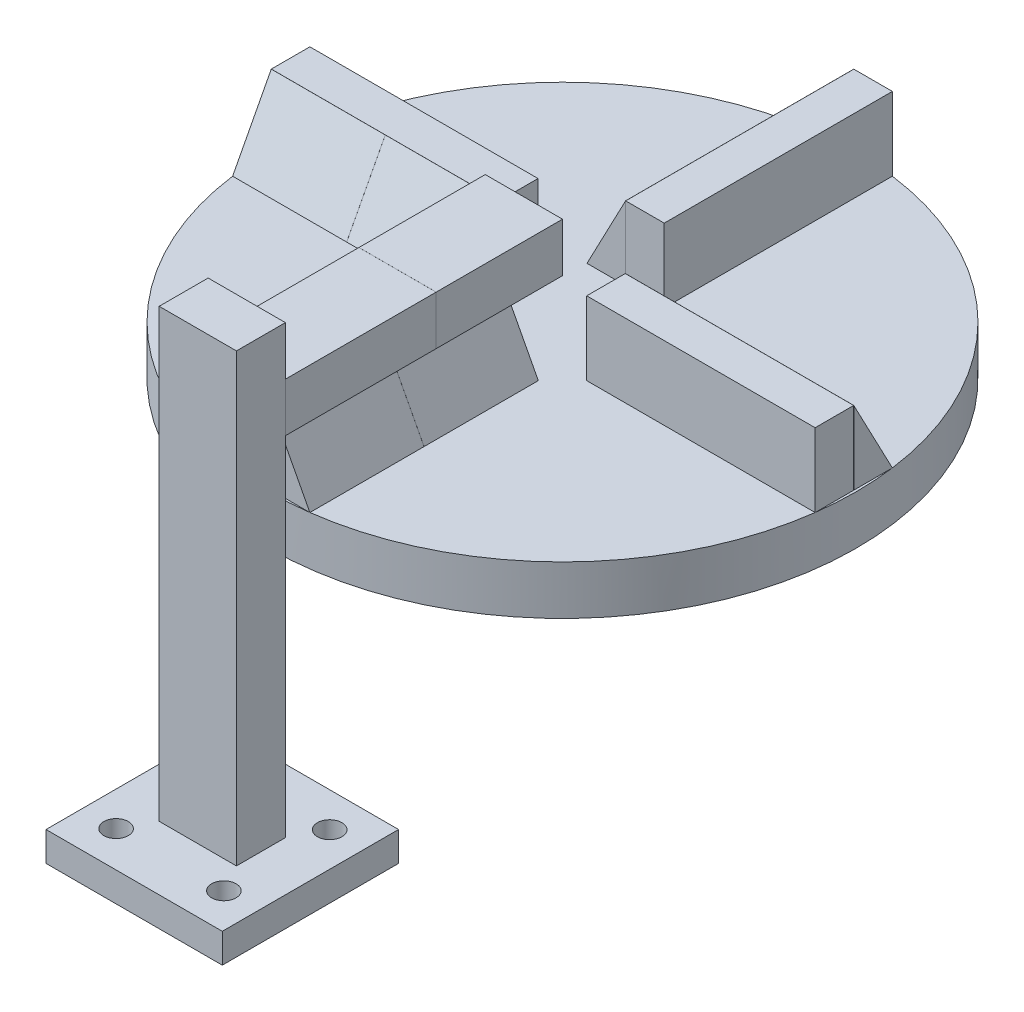
from build123d import *

# Parameters (mm, degrees)
SKETCH1_R                = 60
BOSS_EXTRUDE1_DEPTH      = 10
SKETCH2_R                = 1.5
CUT_EXTRUDE1_DEPTH       = 4
SKETCH3_W                = 15.7752901
SKETCH3_H                = 46.65078099
SKETCH3_W_2              = 46.65078099
SKETCH3_H_2              = 15.7752901
BOSS_EXTRUDE2_DEPTH      = 15
CUT_EXTRUDE2_DEPTH       = 120.479282574
SKETCH5_W                = 0.01
SKETCH5_H                = 15
CUT_EXTRUDE3_DEPTH       = 120.479282574
SKETCH6_W                = 0.01
SKETCH6_H                = 16.947417043
CUT_EXTRUDE4_DEPTH       = 7
CUT_EXTRUDE5_DEPTH       = 120.479282574
SKETCH9_W                = 0.01
SKETCH9_H                = 15
CUT_EXTRUDE6_DEPTH       = 120.479282574
SKETCH12_W               = 15.7752901
SKETCH12_H               = 10
BOSS_EXTRUDE3_DEPTH      = 51.591638
SKETCH14_W               = 15.7752901
SKETCH14_H               = 10
BOSS_EXTRUDE4_DEPTH      = 5
SKETCH13_W               = 0.01
SKETCH13_H               = 10
CUT_EXTRUDE9_DEPTH       = 68.88764505
SKETCH15_W               = 15.7752901
SKETCH15_H               = 10
BOSS_EXTRUDE5_DEPTH      = 10
SKETCH16_W               = 15.7752901
SKETCH16_H               = 10
BOSS_EXTRUDE6_DEPTH      = 10
BOSS_EXTRUDE6_DEPTH_BACK = 54
SKETCH17_W               = 0.01
SKETCH17_H               = 10
CUT_EXTRUDE10_DEPTH      = 68.88764505
SKETCH18_W               = 15.7752901
SKETCH18_H               = 15
CUT_EXTRUDE11_DEPTH      = 46.650781
SKETCH19_W               = 7.87764505
SKETCH19_H               = 15
CUT_EXTRUDE12_DEPTH      = 46.650781
SKETCH20_W               = 46.591637524
SKETCH20_H               = 15.7752901
SKETCH20_W_2             = 15.7752901
SKETCH20_H_2             = 46.591637524
BOSS_EXTRUDE12_DEPTH     = 15
CUT_EXTRUDE13_DEPTH      = 46.591638
CUT_EXTRUDE14_DEPTH      = 51.591638
SKETCH23_W               = 0.01
SKETCH23_H               = 15
CUT_EXTRUDE15_DEPTH      = 48
SKETCH24_W               = 0.01
SKETCH24_H               = 15
CUT_EXTRUDE16_DEPTH      = 48
SKETCH26_W               = 0.01
SKETCH26_H               = 16.947417043
CUT_EXTRUDE18_DEPTH      = 5
SKETCH28_W               = 0.01
SKETCH28_H               = 16.947417043
CUT_EXTRUDE20_DEPTH      = 6
SKETCH29_W               = 0.01
SKETCH29_H               = 16.947417043
CUT_EXTRUDE21_DEPTH      = 6
SKETCH30_W               = 15.7752901
SKETCH30_H               = 10
BOSS_EXTRUDE13_DEPTH     = 33.09
SKETCH31_W               = 36
SKETCH31_H               = 36
BOSS_EXTRUDE14_DEPTH     = 6
SKETCH32_R               = 2.5
CUT_EXTRUDE22_DEPTH      = 6


with BuildPart() as part:
    # Sketch1 → Boss-Extrude1 (new body)
    with BuildSketch(Plane(origin=(0, 0, 0), x_dir=(1, 0, 0), z_dir=(0, 1, 0))):
        Circle(SKETCH1_R)
    extrude(amount=BOSS_EXTRUDE1_DEPTH)

    # Sketch2 → Cut-Extrude1 (cut)
    with BuildSketch(Plane.XZ):
        Circle(SKETCH2_R)
    extrude(amount=-CUT_EXTRUDE1_DEPTH, mode=Mode.SUBTRACT)

    # Sketch3 → Boss-Extrude2 (add)
    with BuildSketch(Plane(origin=(0, 10, 0), x_dir=(1, 0, 0), z_dir=(0, 1, 0))):
        with Locations((0, -36.153892079)):
            Rectangle(SKETCH3_W, SKETCH3_H)
        with Locations((-36.153892079, 0)):
            Rectangle(SKETCH3_W_2, SKETCH3_H_2)
        with Locations((0, 36.153892079)):
            Rectangle(SKETCH3_W, SKETCH3_H)
        with Locations((36.153892079, 0)):
            Rectangle(SKETCH3_W_2, SKETCH3_H_2)
    extrude(amount=BOSS_EXTRUDE2_DEPTH)

    # Sketch4 → Cut-Extrude2 (cut, through all)
    with BuildSketch(Plane.XY.offset(59.479282574)):
        Polygon((0, 25), (7.88764505, 10), (7.88764505, 25), align=None)
    extrude(amount=-CUT_EXTRUDE2_DEPTH, mode=Mode.SUBTRACT)

    # Sketch5 → Cut-Extrude3 (cut, through all)
    with BuildSketch(Plane.XY.offset(59.479282574)):
        with Locations((-0.005, 17.5)):
            Rectangle(SKETCH5_W, SKETCH5_H)
    extrude(amount=-CUT_EXTRUDE3_DEPTH, mode=Mode.SUBTRACT)

    # Sketch6 → Cut-Extrude4 (cut)
    with BuildSketch(Plane(origin=(10.298443557, 5.41536449, 0), x_dir=(0, 0, -1), z_dir=(0.885090628, 0.465418714, 0))):
        with Locations((-36.158892079, 13.653557188)):
            Rectangle(SKETCH6_W, SKETCH6_H)
    extrude(amount=-CUT_EXTRUDE4_DEPTH, mode=Mode.SUBTRACT)

    # Sketch8 → Cut-Extrude5 (cut, through all)
    with BuildSketch(Plane(origin=(59.479282574, 0, 0), x_dir=(0, 0, -1), z_dir=(1, 0, 0))):
        Polygon((0, 25), (7.88764505, 10), (7.88764505, 25), align=None)
    extrude(amount=-CUT_EXTRUDE5_DEPTH, mode=Mode.SUBTRACT)

    # Sketch9 → Cut-Extrude6 (cut, through all)
    with BuildSketch(Plane(origin=(59.479282574, 0, 0), x_dir=(0, 0, -1), z_dir=(1, 0, 0))):
        with Locations((-0.005, 17.5)):
            Rectangle(SKETCH9_W, SKETCH9_H)
    extrude(amount=-CUT_EXTRUDE6_DEPTH, mode=Mode.SUBTRACT)

    # Sketch18 → Cut-Extrude11 (cut)
    with BuildSketch(Plane(origin=(0, 0, -59.479282574), x_dir=(-1, 0, 0), z_dir=(0, 0, -1))):
        with Locations((0, 17.5)):
            Rectangle(SKETCH18_W, SKETCH18_H)
    extrude(amount=-CUT_EXTRUDE11_DEPTH, mode=Mode.SUBTRACT)

    # Sketch19 → Cut-Extrude12 (cut)
    with BuildSketch(Plane.ZY.offset(59.479282574)):
        with Locations((3.948822525, 17.5)):
            Rectangle(SKETCH19_W, SKETCH19_H)
        Polygon((-7.88764505, 10), (0, 10), (0, 25), align=None)
    extrude(amount=-CUT_EXTRUDE12_DEPTH, mode=Mode.SUBTRACT)

    # Sketch20 → Boss-Extrude12 (add)
    with BuildSketch(Plane(origin=(0, 10, 0), x_dir=(1, 0, 0), z_dir=(0, 1, 0))):
        with Locations((-36.183463812, 0)):
            Rectangle(SKETCH20_W, SKETCH20_H)
        with Locations((0, 36.183463812)):
            Rectangle(SKETCH20_W_2, SKETCH20_H_2)
    extrude(amount=BOSS_EXTRUDE12_DEPTH)

    # Sketch21 → Cut-Extrude13 (cut)
    with BuildSketch(Plane(origin=(0, 0, -59.479282574), x_dir=(-1, 0, 0), z_dir=(0, 0, -1))):
        Polygon((0, 25), (7.88764505, 10), (7.88764505, 25), (1.000443781, 25), align=None)
    extrude(amount=-CUT_EXTRUDE13_DEPTH, mode=Mode.SUBTRACT)

    # Sketch22 → Cut-Extrude14 (cut)
    with BuildSketch(Plane.ZY.offset(59.479282574)):
        Polygon((0, 25), (7.88764505, 10), (7.88764505, 25), align=None)
    extrude(amount=-CUT_EXTRUDE14_DEPTH, mode=Mode.SUBTRACT)

    # Sketch23 → Cut-Extrude15 (cut)
    with BuildSketch(Plane.ZY.offset(59.479282574)):
        with Locations((-0.005, 17.5)):
            Rectangle(SKETCH23_W, SKETCH23_H)
    extrude(amount=-CUT_EXTRUDE15_DEPTH, mode=Mode.SUBTRACT)

    # Sketch24 → Cut-Extrude16 (cut)
    with BuildSketch(Plane(origin=(0, 0, -59.479282574), x_dir=(-1, 0, 0), z_dir=(0, 0, -1))):
        with Locations((-0.005, 17.5)):
            Rectangle(SKETCH24_W, SKETCH24_H)
    extrude(amount=-CUT_EXTRUDE16_DEPTH, mode=Mode.SUBTRACT)

    # Sketch26 → Cut-Extrude18 (cut)
    with BuildSketch(Plane(origin=(0, 5.41536449, 10.298443557), x_dir=(1, 0, 0), z_dir=(0, 0.465418714, 0.885090628))):
        with Locations((-36.188463812, 13.653557188)):
            Rectangle(SKETCH26_W, SKETCH26_H)
    extrude(amount=-CUT_EXTRUDE18_DEPTH, mode=Mode.SUBTRACT)

    # Sketch28 → Cut-Extrude20 (cut)
    with BuildSketch(Plane(origin=(0, 5.41536449, -10.298443557), x_dir=(-1, 0, 0), z_dir=(0, 0.465418714, -0.885090628))):
        with Locations((-36.158892079, 13.653557188)):
            Rectangle(SKETCH28_W, SKETCH28_H)
    extrude(amount=-CUT_EXTRUDE20_DEPTH, mode=Mode.SUBTRACT)

    # Sketch29 → Cut-Extrude21 (cut)
    with BuildSketch(Plane(origin=(-10.298443557, 5.41536449, 0), x_dir=(0, 0, 1), z_dir=(-0.885090628, 0.465418714, 0))):
        with Locations((-36.188463812, 13.653557188)):
            Rectangle(SKETCH29_W, SKETCH29_H)
    extrude(amount=-CUT_EXTRUDE21_DEPTH, mode=Mode.SUBTRACT)


with BuildPart() as body_2:
    # Sketch12 → Boss-Extrude3 (new body)
    with BuildSketch(Plane.XY.offset(59.479282574)):
        with Locations((0, 31.08603907)):
            Rectangle(SKETCH12_W, SKETCH12_H)
    extrude(amount=-BOSS_EXTRUDE3_DEPTH)

    # Sketch14 → Boss-Extrude4 (add)
    with BuildSketch(Plane.XY.offset(59.479282574)):
        with Locations((0, 31.08603907)):
            Rectangle(SKETCH14_W, SKETCH14_H)
    extrude(amount=BOSS_EXTRUDE4_DEPTH)

    # Sketch13 → Cut-Extrude9 (cut, through all)
    with BuildSketch(Plane(origin=(7.88764505, 0, 0), x_dir=(0, 0, -1), z_dir=(1, 0, 0))):
        with Locations((-33.688463812, 31.08603907)):
            Rectangle(SKETCH13_W, SKETCH13_H)
    extrude(amount=-CUT_EXTRUDE9_DEPTH, mode=Mode.SUBTRACT)

    # Sketch15 → Boss-Extrude5 (add)
    with BuildSketch(Plane.XY.offset(64.479282574)):
        with Locations((0, 31.08603907)):
            Rectangle(SKETCH15_W, SKETCH15_H)
    extrude(amount=BOSS_EXTRUDE5_DEPTH)

    # Sketch16 → Boss-Extrude6 (add, two sides)
    with BuildSketch(Plane(origin=(0, 36.08603907, 0), x_dir=(1, 0, 0), z_dir=(0, 1, 0))) as boss_extrude6_sk:
        with Locations((0, -69.479282574)):
            Rectangle(SKETCH16_W, SKETCH16_H)
    extrude(amount=BOSS_EXTRUDE6_DEPTH)
    extrude(boss_extrude6_sk.sketch, amount=-BOSS_EXTRUDE6_DEPTH_BACK)

    # Sketch17 → Cut-Extrude10 (cut, through all)
    with BuildSketch(Plane(origin=(7.88764505, 0, 0), x_dir=(0, 0, -1), z_dir=(1, 0, 0))):
        with Locations((-64.474282574, 31.08603907)):
            Rectangle(SKETCH17_W, SKETCH17_H)
    extrude(amount=-CUT_EXTRUDE10_DEPTH, mode=Mode.SUBTRACT)

    # Sketch30 → Boss-Extrude13 (add)
    with BuildSketch(Plane.XZ.offset(17.91396093)):
        with Locations((0, 69.479282574)):
            Rectangle(SKETCH30_W, SKETCH30_H)
    extrude(amount=BOSS_EXTRUDE13_DEPTH)

    # Sketch31 → Boss-Extrude14 (add)
    with BuildSketch(Plane.XZ.offset(51.00396093)):
        with Locations((0, 69.479282574)):
            Rectangle(SKETCH31_W, SKETCH31_H)
    extrude(amount=-BOSS_EXTRUDE14_DEPTH)

    # Sketch32 → Cut-Extrude22 (cut)
    with BuildSketch(Plane.XZ.offset(51.00396093)):
        with Locations((11.001703268, 80.159648752)):
            Circle(SKETCH32_R)
        with Locations((11.001703268, 58.54924963)):
            Circle(SKETCH32_R)
        with Locations((-11.001703268, 58.54924963)):
            Circle(SKETCH32_R)
        with Locations((-11.001703268, 80.159648752)):
            Circle(SKETCH32_R)
    extrude(amount=-CUT_EXTRUDE22_DEPTH, mode=Mode.SUBTRACT)


solid = Compound([part.part, body_2.part])
